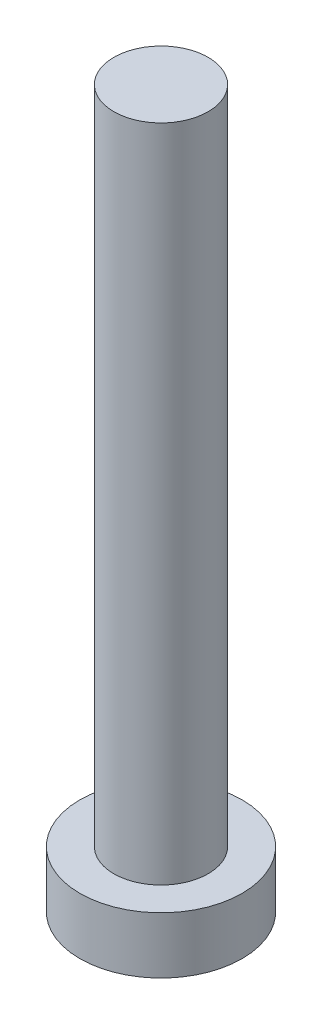
from build123d import *

# Parameters (mm, degrees)
SKETCH_1_R          = 4.3
EXTRUDE_1_DEPTH     = 3
SKETCH_2_R          = 2.5
EXTRUDE_2_DEPTH     = 35
CUT_EXTRUDE_1_DEPTH = 1.5


with BuildPart() as part:
    # 草图1 → 凸台-拉伸1 (new body)
    with BuildSketch(Plane(origin=(0, 0, 0), x_dir=(1, 0, 0), z_dir=(0, 1, 0))):
        Circle(SKETCH_1_R)
    extrude(amount=EXTRUDE_1_DEPTH)

    # 草图2 → 凸台-拉伸2 (add)
    with BuildSketch(Plane(origin=(0, 3, 0), x_dir=(1, 0, 0), z_dir=(0, 1, 0))):
        Circle(SKETCH_2_R)
    extrude(amount=EXTRUDE_2_DEPTH)

    # 草图3 → 切除-拉伸1 (cut)
    with BuildSketch(Plane.XZ):
        with BuildLine():
            Line((-0.6, 1.1), (-0.6, 2.4))
            Line((-0.6, 2.4), (0.6, 2.4))
            Line((0.6, 2.4), (0.6, 1.1))
            ThreePointArc((0.6, 1.1), (0.746446609, 0.746446609), (1.1, 0.6))
            Line((1.1, 0.6), (2.4, 0.6))
            Line((2.4, 0.6), (2.4, -0.6))
            Line((2.4, -0.6), (1.1, -0.6))
            ThreePointArc((1.1, -0.6), (0.746446609, -0.746446609), (0.6, -1.1))
            Line((0.6, -1.1), (0.6, -2.4))
            Line((0.6, -2.4), (-0.6, -2.4))
            Line((-0.6, -2.4), (-0.6, -1.1))
            ThreePointArc((-0.6, -1.1), (-0.746446609, -0.746446609), (-1.1, -0.6))
            Line((-1.1, -0.6), (-2.4, -0.6))
            Line((-2.4, -0.6), (-2.4, 0.6))
            Line((-2.4, 0.6), (-1.1, 0.6))
            ThreePointArc((-1.1, 0.6), (-0.746446609, 0.746446609), (-0.6, 1.1))
        make_face()
    extrude(amount=-CUT_EXTRUDE_1_DEPTH, mode=Mode.SUBTRACT)


solid = part.part
